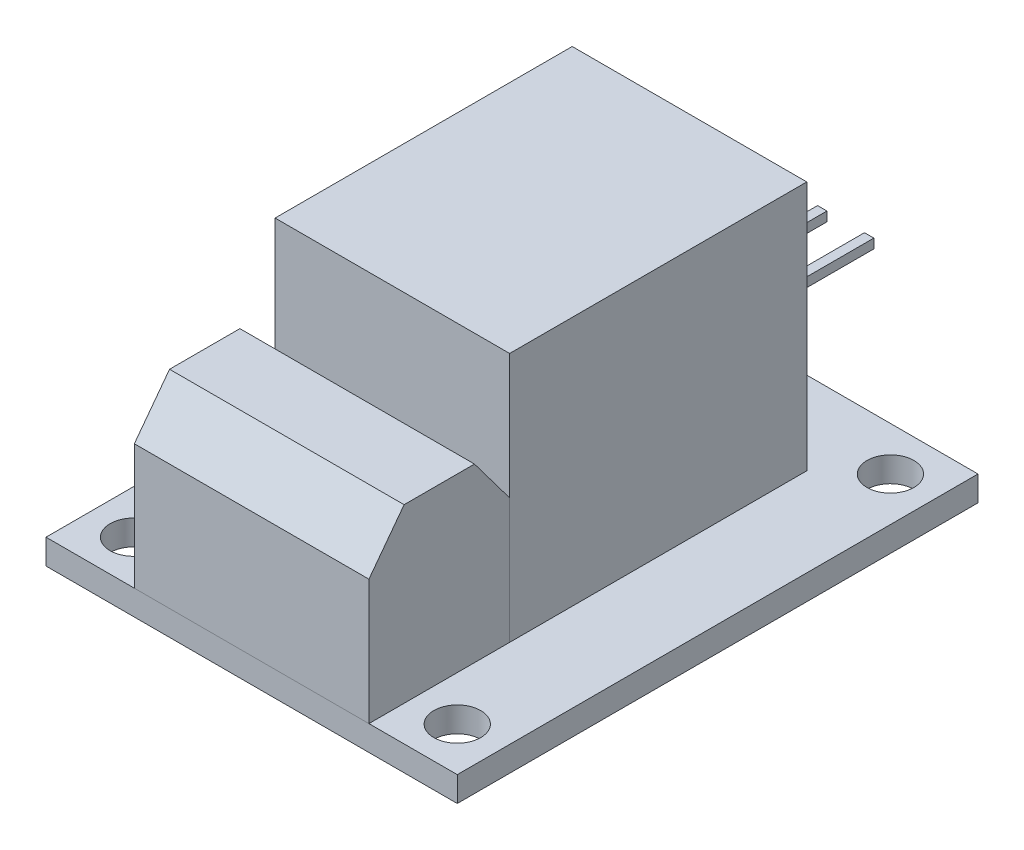
from build123d import *

# Parameters (mm, degrees)
SKETCH2_W       = 26.3
SKETCH2_H       = 33.3
EXTRUDE1_DEPTH  = 1.6
SKETCH3_W       = 15
SKETCH3_H       = 19
EXTRUDE2_DEPTH  = 16
SKETCH4_W       = 15
SKETCH4_H       = 9
EXTRUDE3_DEPTH  = 11
EXTRUDE5_DEPTH  = 21.65
SKETCH8_W       = 8
SKETCH8_H       = 3
EXTRUDE6_DEPTH  = 4.5
SKETCH9_W       = 0.6
SKETCH9_H       = 0.6
EXTRUDE9_DEPTH  = 7
SKETCH10_R      = 1.5
EXTRUDE10_DEPTH = 18.6


with BuildPart() as part:
    # Sketch2 → Extrude1 (new body)
    with BuildSketch(Plane(origin=(0, 0, 0), x_dir=(1, 0, 0), z_dir=(0, 1, 0))):
        Rectangle(SKETCH2_W, SKETCH2_H)
    extrude(amount=EXTRUDE1_DEPTH)

    # Sketch3 → Extrude2 (add)
    with BuildSketch(Plane(origin=(0, 1.6, 0), x_dir=(1, 0, 0), z_dir=(0, 1, 0))):
        with Locations((0, 1.85)):
            Rectangle(SKETCH3_W, SKETCH3_H)
    extrude(amount=EXTRUDE2_DEPTH)

    # Sketch8 → Extrude6 (add)
    with BuildSketch(Plane(origin=(0, 1.6, 0), x_dir=(1, 0, 0), z_dir=(0, 1, 0))):
        with Locations((-2.65, 13.85)):
            Rectangle(SKETCH8_W, SKETCH8_H)
    extrude(amount=EXTRUDE6_DEPTH)

    # Sketch9 → Extrude9 (add)
    with BuildSketch(Plane(origin=(0, 0, -15.35), x_dir=(-1, 0, 0), z_dir=(0, 0, -1))):
        with Locations((2.508816384, 5.335265534)):
            Rectangle(SKETCH9_W, SKETCH9_H)
        with Locations((-0.491183616, 5.335265534)):
            Rectangle(SKETCH9_W, SKETCH9_H)
        with Locations((5.508816384, 5.335265534)):
            Rectangle(SKETCH9_W, SKETCH9_H)
    extrude(amount=EXTRUDE9_DEPTH)

    # Sketch10 → Extrude10 (cut, through all)
    with BuildSketch(Plane(origin=(0, 0, 0), x_dir=(1, 0, 0), z_dir=(0, 1, 0))):
        with Locations((-10.35, -13.85)):
            Circle(SKETCH10_R)
        with Locations((10.35, -13.85)):
            Circle(SKETCH10_R)
        with Locations((10.35, 13.85)):
            Circle(SKETCH10_R)
        with Locations((-10.35, 13.85)):
            Circle(SKETCH10_R)
    extrude(amount=EXTRUDE10_DEPTH, mode=Mode.SUBTRACT)


with BuildPart() as body_2:
    # Sketch4 → Extrude3 (new body)
    with BuildSketch(Plane(origin=(0, 1.6, 0), x_dir=(1, 0, 0), z_dir=(0, 1, 0))):
        with Locations((0, -12.15)):
            Rectangle(SKETCH4_W, SKETCH4_H)
    extrude(amount=EXTRUDE3_DEPTH)

    # Sketch7 → Extrude5 (cut, through all)
    with BuildSketch(Plane.ZY.offset(7.5)):
        Polygon((9.9, 12.6), (7.65, 9.6), (7.65, 12.6), align=None)
        Polygon((16.65, 9.6), (16.65, 12.6), (14.4, 12.6), align=None)
    extrude(amount=-EXTRUDE5_DEPTH, mode=Mode.SUBTRACT)


solid = Compound([part.part, body_2.part])
